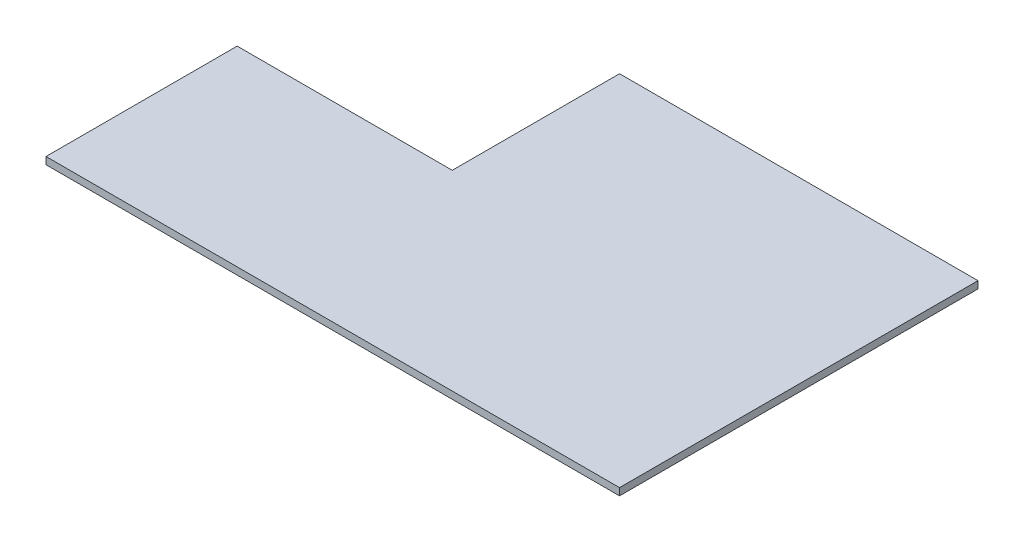
from build123d import *

# Parameters (mm, degrees)
BOSS_EXTRUDE1_DEPTH = 3


with BuildPart() as part:
    # Sketch1 → Boss-Extrude1 (new body)
    with BuildSketch(Plane(origin=(0, 0, 0), x_dir=(1, 0, 0), z_dir=(0, 1, 0))):
        Polygon((120, 132.068965517), (120, -17.931034483), (-120, -17.931034483), (-120, 62.068965517), (-30, 62.068965517), (-30, 132.068965517), align=None)
    extrude(amount=BOSS_EXTRUDE1_DEPTH)


solid = part.part
